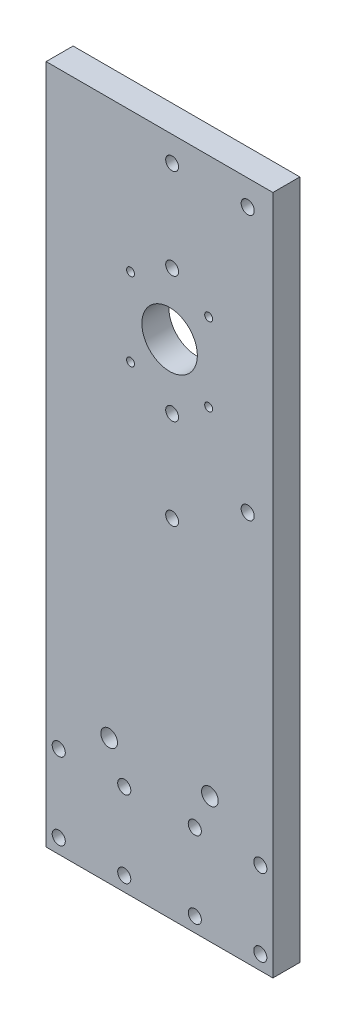
from build123d import *

# Parameters (mm, degrees)
ESBO_O1_W                               = 90
ESBO_O1_H                               = 270
RESSALTO_EXTRUS_O1_DEPTH                = 10.7
FURO_ROSCADO_PARA_CONDU_TE_DE_M5X0_81_D = 5.2
FURO_ROSCADO_PARA_CONDU_TE_DE_1_4_281_D = 6.6294
FURO_ROSCADO_PARA_CONDU_TE_DE_M5X0_82_D = 5.2
FURO_ROSCADO_PARA_CONDU_TE_DE_10_321_D  = 5.1054
ESBO_O14_R                              = 11
CORTE_EXTRUS_O1_DEPTH                   = 11.7
FURO_ROSCADO_PARA_CONDU_TE_DE_M3X0_51_D = 3.15


with BuildPart() as part:
    # Esboço1 → Ressalto-extrusão1 (new body)
    with BuildSketch(Plane.XY):
        Rectangle(ESBO_O1_W, ESBO_O1_H)
    extrude(amount=RESSALTO_EXTRUS_O1_DEPTH)

    # Furo roscado para conduíte de M5x0.81 (through all)
    with Locations(Plane(origin=(0, 0, 0), x_dir=(-1, 0, 0), z_dir=(0, 0, -1))):
        with Locations((-40, -98.75), (-14, -98.75), (-40, -129.25), (-14, -129.25), (14, -129.25), (40, -129.25), (14, -98.75), (40, -98.75)):
            Hole(FURO_ROSCADO_PARA_CONDU_TE_DE_M5X0_81_D / 2)

    # Furo roscado para conduíte de 1/4-281 (through all)
    with Locations(Plane(origin=(0, 0, 0), x_dir=(-1, 0, 0), z_dir=(0, 0, -1))):
        with Locations((-20, -85), (20, -85)):
            Hole(FURO_ROSCADO_PARA_CONDU_TE_DE_1_4_281_D / 2)

    # Furo roscado para conduíte de M5x0.82 (through all)
    with Locations(Plane(origin=(0, 0, 0), x_dir=(-1, 0, 0), z_dir=(0, 0, -1))):
        with Locations((-35, 125), (-35, 20)):
            Hole(FURO_ROSCADO_PARA_CONDU_TE_DE_M5X0_82_D / 2)

    # Furo roscado para conduíte de #10-321 (through all)
    with Locations(Plane(origin=(0, 0, 0), x_dir=(-1, 0, 0), z_dir=(0, 0, -1))):
        with Locations((-5, 125), (-5, 89), (-5, 39), (-5, 3)):
            Hole(FURO_ROSCADO_PARA_CONDU_TE_DE_10_321_D / 2)

    # Esboço14 → Corte-extrusão1 (cut, through all)
    with BuildSketch(Plane(origin=(0, 0, 0), x_dir=(-1, 0, 0), z_dir=(0, 0, -1))):
        with Locations((-4, 64)):
            Circle(ESBO_O14_R)
    extrude(amount=-CORTE_EXTRUS_O1_DEPTH, mode=Mode.SUBTRACT)

    # Furo roscado para conduíte de M3x0.51 (through all)
    with Locations(Plane(origin=(0, 0, 0), x_dir=(-1, 0, 0), z_dir=(0, 0, -1))):
        with Locations((-19.5, 79.5), (-19.5, 48.5), (11.5, 79.5), (11.5, 48.5)):
            Hole(FURO_ROSCADO_PARA_CONDU_TE_DE_M3X0_51_D / 2)


solid = part.part
